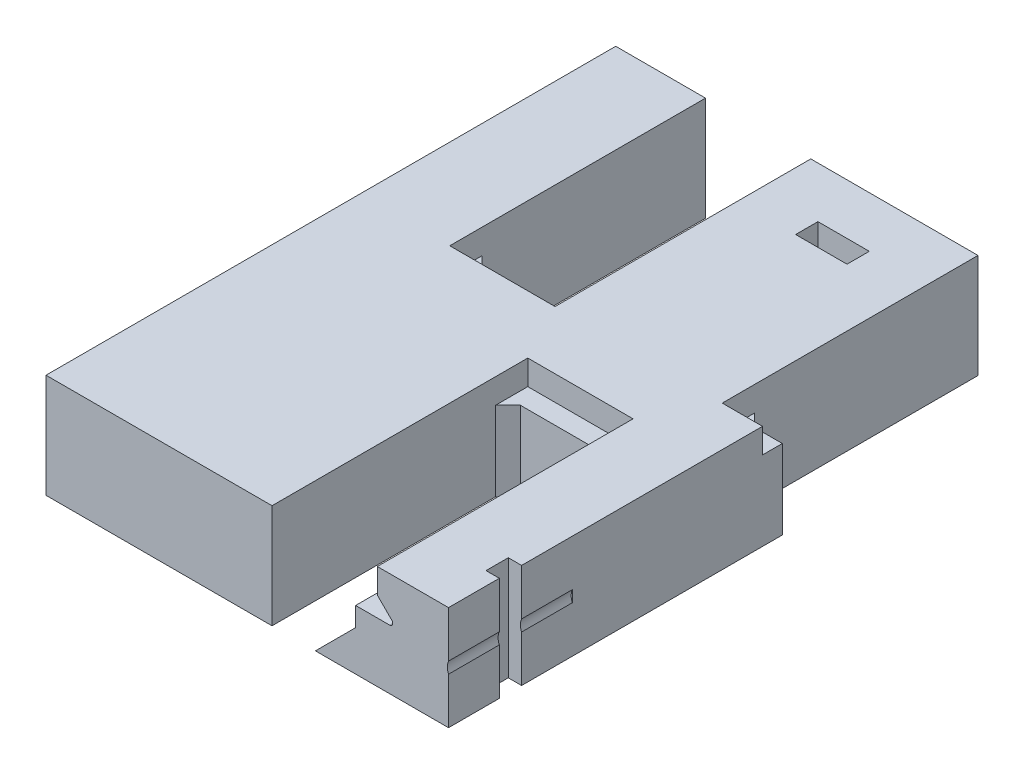
from build123d import *

# Parameters (mm, degrees)
SKETCH1_W               = 78
SKETCH1_H               = 46
BOSS_EXTRUDE1_DEPTH     = 4.2
SKETCH2_W               = 8.5
SKETCH2_H               = 2
CUT_EXTRUDE1_DEPTH      = 20.65
CUT_EXTRUDE2_DEPTH      = 7.4
BOSS_EXTRUDE3_DEPTH     = 23
LPATTERN1_COUNT         = 6
LPATTERN1_PITCH         = 11
MIRROR3_COPY_1_SKETCH_W = 8.5
MIRROR3_COPY_1_SKETCH_H = 2
MIRROR3_COPY_1_DEPTH    = 20.65
MIRROR3_COPY_2_SKETCH_W = 8.5
MIRROR3_COPY_2_SKETCH_H = 2
MIRROR3_COPY_2_DEPTH    = 20.65
MIRROR3_COPY_3_SKETCH_W = 8.5
MIRROR3_COPY_3_SKETCH_H = 2
MIRROR3_COPY_3_DEPTH    = 20.65
MIRROR3_COPY_4_SKETCH_W = 8.5
MIRROR3_COPY_4_SKETCH_H = 2
MIRROR3_COPY_4_DEPTH    = 20.65
MIRROR3_COPY_5_SKETCH_W = 8.5
MIRROR3_COPY_5_SKETCH_H = 2
MIRROR3_COPY_5_DEPTH    = 20.65
MIRROR3_COPY_6_DEPTH    = 7.4
MIRROR3_COPY_7_DEPTH    = 7.4
MIRROR3_COPY_8_DEPTH    = 7.4
MIRROR3_COPY_9_DEPTH    = 7.4
MIRROR3_COPY_10_DEPTH   = 7.4
MIRROR3_COPY_11_DEPTH   = 23
MIRROR3_COPY_12_DEPTH   = 23
MIRROR3_COPY_13_DEPTH   = 23
MIRROR3_COPY_14_DEPTH   = 23
MIRROR3_COPY_15_DEPTH   = 23
SKETCH6_W               = 8.5
SKETCH6_H               = 20.65
BOSS_EXTRUDE2_DEPTH     = 8.4
SKETCH4_R               = 1.5
CUT_EXTRUDE3_DEPTH      = 5
SKETCH7_R               = 1.1
CUT_EXTRUDE4_DEPTH      = 10
SKETCH9_W               = 4.15
SKETCH9_H               = 1.8
CUT_EXTRUDE5_DEPTH      = 9.4
SKETCH10_W              = 4.15
SKETCH10_H              = 1.8
CUT_EXTRUDE6_DEPTH      = 9.4
SKETCH11_R              = 1.1
CUT_EXTRUDE7_DEPTH      = 8
LPATTERN2_COUNT         = 2
LPATTERN2_PITCH         = 22
CUT_EXTRUDE8_DEPTH      = 19.05
CUT_EXTRUDE9_DEPTH      = 19.05
LPATTERN3_COUNT         = 3
LPATTERN3_PITCH         = 22
LPATTERN4_COUNT         = 3
LPATTERN4_PITCH         = 22
FILLET1_R               = 0.25


with BuildPart() as part:
    # Sketch1 → Boss-Extrude1 (new body, symmetric)
    with BuildSketch(Plane(origin=(0, 0, 0), x_dir=(1, 0, 0), z_dir=(0, 1, 0))):
        Rectangle(SKETCH1_W, SKETCH1_H)
    extrude(amount=BOSS_EXTRUDE1_DEPTH, both=True)

    # Sketch2 → Cut-Extrude1 (cut)
    with BuildSketch(Plane(origin=(0, 0, -23), x_dir=(-1, 0, 0), z_dir=(0, 0, -1))):
        with Locations((-27.5, 3.2)):
            Rectangle(SKETCH2_W, SKETCH2_H)
    cut_extrude1 = extrude(amount=-CUT_EXTRUDE1_DEPTH, mode=Mode.SUBTRACT)

    # Sketch3 → Cut-Extrude2 (cut, through all)
    with BuildSketch(Plane(origin=(0, 2.2, 0), x_dir=(1, 0, 0), z_dir=(0, 1, 0))):
        Polygon((24.25, 21.3), (23.25, 20.3), (23.25, 4.95), (24.25, 3.95), (30, 3.95), (30, 21.3), align=None)
        Polygon((30, 23), (23.25, 23), (23.25, 20.3), (24.25, 21.3), (30, 21.3), align=None)
    cut_extrude2 = extrude(amount=-CUT_EXTRUDE2_DEPTH, mode=Mode.SUBTRACT)

    # Sketch15 → Boss-Extrude3 (add)
    with BuildSketch(Plane.XY):
        Polygon((30, -4.2), (26.75, -4.2), (30, -0.95), align=None)
    boss_extrude3 = extrude(amount=-BOSS_EXTRUDE3_DEPTH)

    # LPattern1: Cut-Extrude1, Cut-Extrude2, Boss-Extrude3 ×6
    with Locations(*[(-i * LPATTERN1_PITCH, 0, 0) for i in range(1, LPATTERN1_COUNT)]):
        add(cut_extrude1, mode=Mode.SUBTRACT)
        add(cut_extrude2, mode=Mode.SUBTRACT)
        add(boss_extrude3)

    # Mirror3: Cut-Extrude1, Cut-Extrude2, Boss-Extrude3 across plane
    add(cut_extrude1.mirror(Plane.XY), mode=Mode.SUBTRACT)
    add(cut_extrude2.mirror(Plane.XY), mode=Mode.SUBTRACT)
    add(boss_extrude3.mirror(Plane.XY))

    # Mirror3 copy 1 sketch → Mirror3 copy 1 (cut)
    with BuildSketch(Plane(origin=(-11, 0, 23), x_dir=(-1, 0, 0), z_dir=(0, 0, 1))):
        with Locations((-27.5, -3.2)):
            Rectangle(MIRROR3_COPY_1_SKETCH_W, MIRROR3_COPY_1_SKETCH_H)
    extrude(amount=-MIRROR3_COPY_1_DEPTH, mode=Mode.SUBTRACT)

    # Mirror3 copy 2 sketch → Mirror3 copy 2 (cut)
    with BuildSketch(Plane(origin=(-22, 0, 23), x_dir=(-1, 0, 0), z_dir=(0, 0, 1))):
        with Locations((-27.5, -3.2)):
            Rectangle(MIRROR3_COPY_2_SKETCH_W, MIRROR3_COPY_2_SKETCH_H)
    extrude(amount=-MIRROR3_COPY_2_DEPTH, mode=Mode.SUBTRACT)

    # Mirror3 copy 3 sketch → Mirror3 copy 3 (cut)
    with BuildSketch(Plane(origin=(-33, 0, 23), x_dir=(-1, 0, 0), z_dir=(0, 0, 1))):
        with Locations((-27.5, -3.2)):
            Rectangle(MIRROR3_COPY_3_SKETCH_W, MIRROR3_COPY_3_SKETCH_H)
    extrude(amount=-MIRROR3_COPY_3_DEPTH, mode=Mode.SUBTRACT)

    # Mirror3 copy 4 sketch → Mirror3 copy 4 (cut)
    with BuildSketch(Plane(origin=(-44, 0, 23), x_dir=(-1, 0, 0), z_dir=(0, 0, 1))):
        with Locations((-27.5, -3.2)):
            Rectangle(MIRROR3_COPY_4_SKETCH_W, MIRROR3_COPY_4_SKETCH_H)
    extrude(amount=-MIRROR3_COPY_4_DEPTH, mode=Mode.SUBTRACT)

    # Mirror3 copy 5 sketch → Mirror3 copy 5 (cut)
    with BuildSketch(Plane(origin=(-55, 0, 23), x_dir=(-1, 0, 0), z_dir=(0, 0, 1))):
        with Locations((-27.5, -3.2)):
            Rectangle(MIRROR3_COPY_5_SKETCH_W, MIRROR3_COPY_5_SKETCH_H)
    extrude(amount=-MIRROR3_COPY_5_DEPTH, mode=Mode.SUBTRACT)

    # Mirror3 copy 6 sketch → Mirror3 copy 6 (cut, through all)
    with BuildSketch(Plane(origin=(-11, 2.2, 0), x_dir=(1, 0, 0), z_dir=(0, 1, 0))):
        Polygon((24.25, -21.3), (23.25, -20.3), (23.25, -4.95), (24.25, -3.95), (30, -3.95), (30, -21.3), align=None)
        Polygon((30, -23), (23.25, -23), (23.25, -20.3), (24.25, -21.3), (30, -21.3), align=None)
    extrude(amount=-MIRROR3_COPY_6_DEPTH, mode=Mode.SUBTRACT)

    # Mirror3 copy 7 sketch → Mirror3 copy 7 (cut, through all)
    with BuildSketch(Plane(origin=(-22, 2.2, 0), x_dir=(1, 0, 0), z_dir=(0, 1, 0))):
        Polygon((24.25, -21.3), (23.25, -20.3), (23.25, -4.95), (24.25, -3.95), (30, -3.95), (30, -21.3), align=None)
        Polygon((30, -23), (23.25, -23), (23.25, -20.3), (24.25, -21.3), (30, -21.3), align=None)
    extrude(amount=-MIRROR3_COPY_7_DEPTH, mode=Mode.SUBTRACT)

    # Mirror3 copy 8 sketch → Mirror3 copy 8 (cut, through all)
    with BuildSketch(Plane(origin=(-33, 2.2, 0), x_dir=(1, 0, 0), z_dir=(0, 1, 0))):
        Polygon((24.25, -21.3), (23.25, -20.3), (23.25, -4.95), (24.25, -3.95), (30, -3.95), (30, -21.3), align=None)
        Polygon((30, -23), (23.25, -23), (23.25, -20.3), (24.25, -21.3), (30, -21.3), align=None)
    extrude(amount=-MIRROR3_COPY_8_DEPTH, mode=Mode.SUBTRACT)

    # Mirror3 copy 9 sketch → Mirror3 copy 9 (cut, through all)
    with BuildSketch(Plane(origin=(-44, 2.2, 0), x_dir=(1, 0, 0), z_dir=(0, 1, 0))):
        Polygon((24.25, -21.3), (23.25, -20.3), (23.25, -4.95), (24.25, -3.95), (30, -3.95), (30, -21.3), align=None)
        Polygon((30, -23), (23.25, -23), (23.25, -20.3), (24.25, -21.3), (30, -21.3), align=None)
    extrude(amount=-MIRROR3_COPY_9_DEPTH, mode=Mode.SUBTRACT)

    # Mirror3 copy 10 sketch → Mirror3 copy 10 (cut, through all)
    with BuildSketch(Plane(origin=(-55, 2.2, 0), x_dir=(1, 0, 0), z_dir=(0, 1, 0))):
        Polygon((24.25, -21.3), (23.25, -20.3), (23.25, -4.95), (24.25, -3.95), (30, -3.95), (30, -21.3), align=None)
        Polygon((30, -23), (23.25, -23), (23.25, -20.3), (24.25, -21.3), (30, -21.3), align=None)
    extrude(amount=-MIRROR3_COPY_10_DEPTH, mode=Mode.SUBTRACT)

    # Mirror3 copy 11 sketch → Mirror3 copy 11 (add)
    with BuildSketch(Plane(origin=(-11, 0, 0), x_dir=(1, 0, 0), z_dir=(0, 0, -1))):
        Polygon((30, 4.2), (26.75, 4.2), (30, 0.95), align=None)
    extrude(amount=-MIRROR3_COPY_11_DEPTH)

    # Mirror3 copy 12 sketch → Mirror3 copy 12 (add)
    with BuildSketch(Plane(origin=(-22, 0, 0), x_dir=(1, 0, 0), z_dir=(0, 0, -1))):
        Polygon((30, 4.2), (26.75, 4.2), (30, 0.95), align=None)
    extrude(amount=-MIRROR3_COPY_12_DEPTH)

    # Mirror3 copy 13 sketch → Mirror3 copy 13 (add)
    with BuildSketch(Plane(origin=(-33, 0, 0), x_dir=(1, 0, 0), z_dir=(0, 0, -1))):
        Polygon((30, 4.2), (26.75, 4.2), (30, 0.95), align=None)
    extrude(amount=-MIRROR3_COPY_13_DEPTH)

    # Mirror3 copy 14 sketch → Mirror3 copy 14 (add)
    with BuildSketch(Plane(origin=(-44, 0, 0), x_dir=(1, 0, 0), z_dir=(0, 0, -1))):
        Polygon((30, 4.2), (26.75, 4.2), (30, 0.95), align=None)
    extrude(amount=-MIRROR3_COPY_14_DEPTH)

    # Mirror3 copy 15 sketch → Mirror3 copy 15 (add)
    with BuildSketch(Plane(origin=(-55, 0, 0), x_dir=(1, 0, 0), z_dir=(0, 0, -1))):
        Polygon((30, 4.2), (26.75, 4.2), (30, 0.95), align=None)
    extrude(amount=-MIRROR3_COPY_15_DEPTH)

    # Sketch6 → Boss-Extrude2 (add)
    with BuildSketch(Plane(origin=(0, 4.2, 0), x_dir=(1, 0, 0), z_dir=(0, 1, 0))):
        with Locations((-16.5, 12.675)):
            Rectangle(SKETCH6_W, SKETCH6_H)
        with Locations((5.5, 12.675)):
            Rectangle(SKETCH6_W, SKETCH6_H)
        with Locations((27.5, 12.675)):
            Rectangle(SKETCH6_W, SKETCH6_H)
        with Locations((-27.5, -12.675)):
            Rectangle(SKETCH6_W, SKETCH6_H)
        with Locations((-5.5, -12.675)):
            Rectangle(SKETCH6_W, SKETCH6_H)
        with Locations((16.5, -12.675)):
            Rectangle(SKETCH6_W, SKETCH6_H)
    extrude(amount=-BOSS_EXTRUDE2_DEPTH)

    # Sketch4 → Cut-Extrude3 (cut)
    with BuildSketch(Plane.ZY.offset(39)):
        with Locations((-20, -2.2)):
            Circle(SKETCH4_R)
        with Locations((20, -2.2)):
            Circle(SKETCH4_R)
    cut_extrude3 = extrude(amount=-CUT_EXTRUDE3_DEPTH, mode=Mode.SUBTRACT)

    # Mirror1: Cut-Extrude3 across plane
    add(cut_extrude3.mirror(Plane(origin=(0, 0, 0), x_dir=(0, 0, 1), z_dir=(1, 0, 0))), mode=Mode.SUBTRACT)

    # Sketch7 → Cut-Extrude4 (cut)
    with BuildSketch(Plane.XY.offset(23)):
        with Locations((-5.5, 0)):
            Circle(SKETCH7_R)
        with Locations((16.5, 0)):
            Circle(SKETCH7_R)
    extrude(amount=-CUT_EXTRUDE4_DEPTH, mode=Mode.SUBTRACT)

    # Sketch9 → Cut-Extrude5 (cut, through all)
    with BuildSketch(Plane(origin=(0, 4.2, 0), x_dir=(1, 0, 0), z_dir=(0, 1, 0))):
        with Locations((-5.5, -18)):
            Rectangle(SKETCH9_W, SKETCH9_H)
        Polygon((18.575, -18.9), (14.425, -17.1), (14.425, -18.9), align=None)
        Polygon((18.575, -17.1), (14.425, -17.1), (18.575, -18.9), align=None)
    extrude(amount=-CUT_EXTRUDE5_DEPTH, mode=Mode.SUBTRACT)

    # Sketch10 → Cut-Extrude6 (cut, through all)
    with BuildSketch(Plane(origin=(0, 4.2, 0), x_dir=(1, 0, 0), z_dir=(0, 1, 0))):
        with Locations((-16.5, 18)):
            Rectangle(SKETCH10_W, SKETCH10_H)
    cut_extrude6 = extrude(amount=-CUT_EXTRUDE6_DEPTH, mode=Mode.SUBTRACT)

    # Sketch11 → Cut-Extrude7 (cut)
    with BuildSketch(Plane(origin=(0, 0, -23), x_dir=(-1, 0, 0), z_dir=(0, 0, -1))):
        with Locations((16.5, 0)):
            Circle(SKETCH11_R)
    cut_extrude7 = extrude(amount=-CUT_EXTRUDE7_DEPTH, mode=Mode.SUBTRACT)

    # LPattern2: Cut-Extrude6, Cut-Extrude7 ×2
    with Locations(*[(i * LPATTERN2_PITCH, 0, 0) for i in range(1, LPATTERN2_COUNT)]):
        add(cut_extrude6, mode=Mode.SUBTRACT)
        add(cut_extrude7, mode=Mode.SUBTRACT)

    # Sketch12 → Cut-Extrude8 (cut)
    with BuildSketch(Plane(origin=(0, 0, -23), x_dir=(-1, 0, 0), z_dir=(0, 0, -1))):
        Polygon((-20.75, 2.2), (-22.35, 0.6), (-19, 0.6), (-19, 2.2), align=None)
    cut_extrude8 = extrude(amount=-CUT_EXTRUDE8_DEPTH, mode=Mode.SUBTRACT)

    # Sketch13 → Cut-Extrude9 (cut)
    with BuildSketch(Plane.XY.offset(23)):
        Polygon((31.75, 2.2), (33.35, 0.6), (30, 0.6), (30, 2.2), align=None)
    cut_extrude9 = extrude(amount=-CUT_EXTRUDE9_DEPTH, mode=Mode.SUBTRACT)

    # LPattern3: Cut-Extrude8 ×3
    with Locations(*[(-i * LPATTERN3_PITCH, 0, 0) for i in range(1, LPATTERN3_COUNT)]):
        add(cut_extrude8, mode=Mode.SUBTRACT)

    # LPattern4: Cut-Extrude9 ×3
    with Locations(*[(-i * LPATTERN4_PITCH, 0, 0) for i in range(1, LPATTERN4_COUNT)]):
        add(cut_extrude9, mode=Mode.SUBTRACT)

    # Fillet1
    fillet1_edges = [part.edges().sort_by_distance(p)[0] for p in [
        (22.35, 0.6, -13.475),
        (33.35, 0.6, 13.475),
        (0.35, 0.6, -13.475),
        (-21.65, 0.6, -13.475),
        (11.35, 0.6, 13.475),
        (-10.65, 0.6, 13.475),
    ]]
    fillet(fillet1_edges, radius=FILLET1_R)


with BuildPart() as body_2:
    # Split1: the piece on the far side of the plane
    add(part.part)
    split(bisect_by=Plane(origin=(-6.5, 0, 0), x_dir=(0, 0, 1), z_dir=(1, 0, 0)), keep=Keep.BOTTOM)


with BuildPart() as part_1:
    add(part.part)

    # Split1
    split(bisect_by=Plane(origin=(-6.5, 0, 0), x_dir=(0, 0, 1), z_dir=(1, 0, 0)), keep=Keep.TOP)


solid = body_2.part
